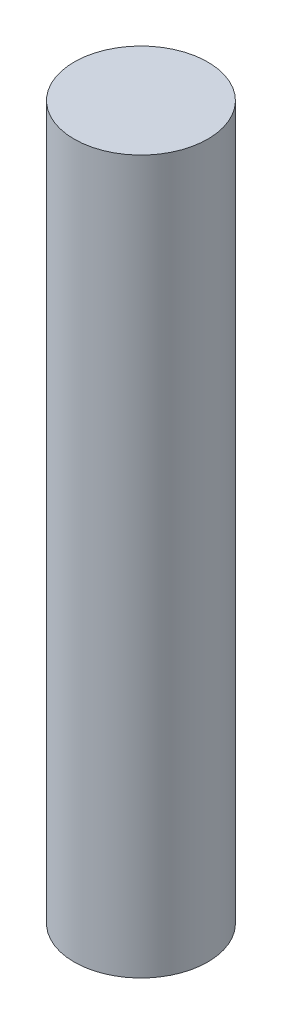
from build123d import *

# Parameters (mm, degrees)
SKETCH1_R           = 0.75
BOSS_EXTRUDE1_DEPTH = 8


with BuildPart() as part:
    # Sketch1 → Boss-Extrude1 (new body)
    with BuildSketch(Plane(origin=(0, 0, 0), x_dir=(1, 0, 0), z_dir=(0, 1, 0))):
        Circle(SKETCH1_R)
    extrude(amount=BOSS_EXTRUDE1_DEPTH)


solid = part.part
